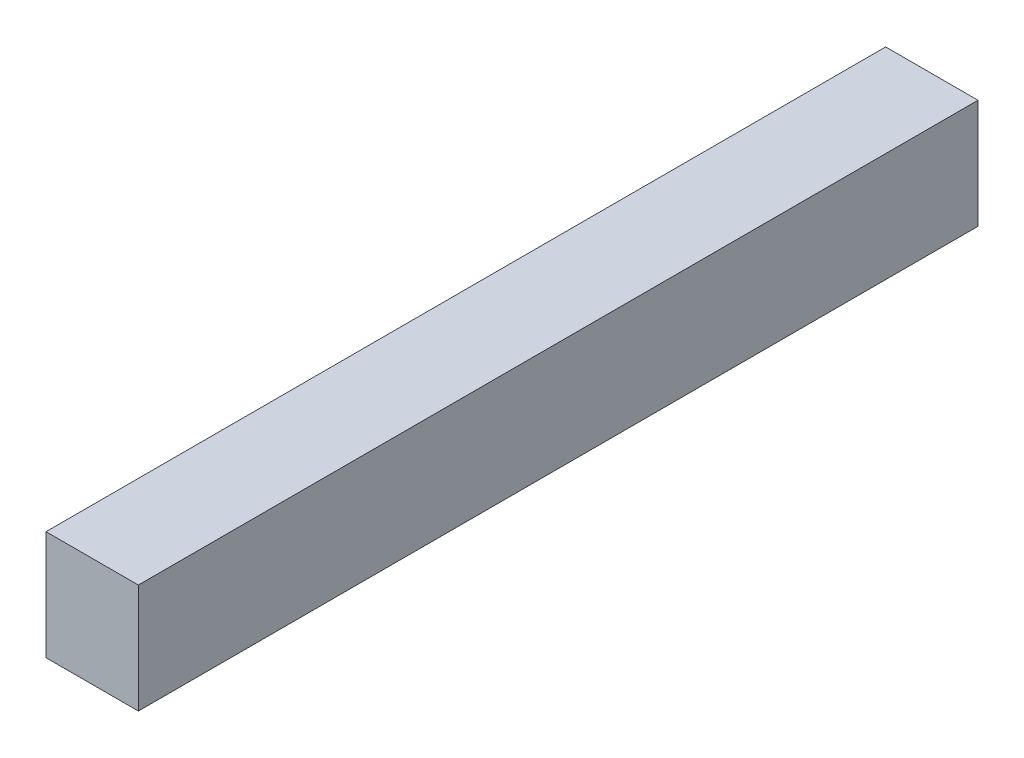
from build123d import *

# Parameters (mm, degrees)
SKETCH1_W           = 2.75
SKETCH1_H           = 3.25
BOSS_EXTRUDE1_DEPTH = 25


with BuildPart() as part:
    # Sketch1 → Boss-Extrude1 (new body)
    with BuildSketch(Plane.XY):
        Rectangle(SKETCH1_W, SKETCH1_H)
    extrude(amount=BOSS_EXTRUDE1_DEPTH)


solid = part.part
